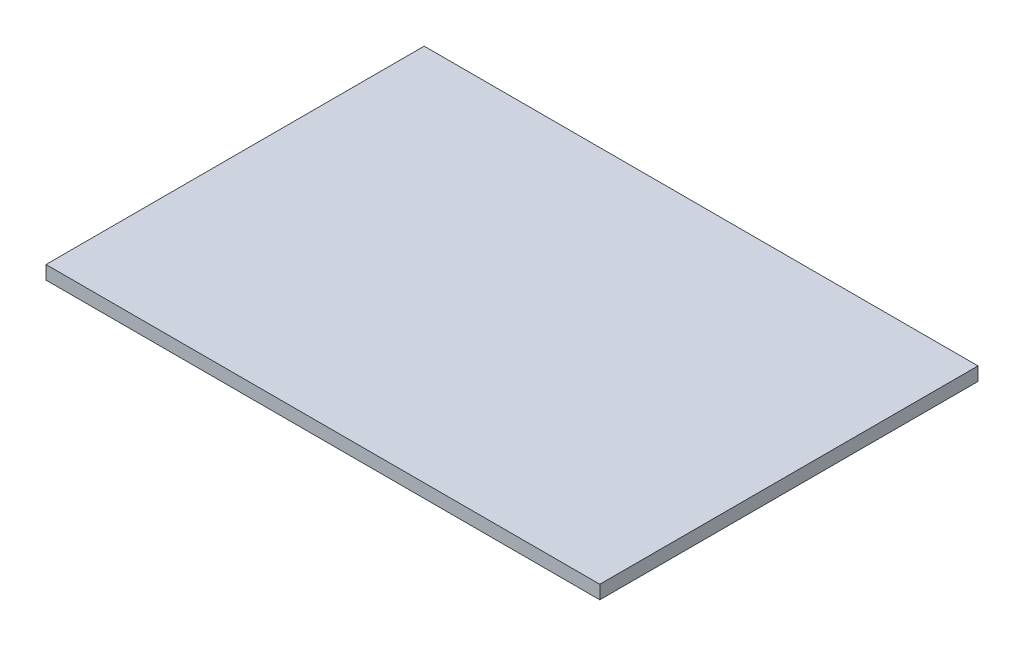
from build123d import *

# Parameters (mm, degrees)
SKETCH_1_W      = 41
SKETCH_1_H      = 28
EXTRUDE_1_DEPTH = 1


with BuildPart() as part:
    # Эскиз1 → Бобышка-Вытянуть1 (new body)
    with BuildSketch(Plane(origin=(0, 0, 0), x_dir=(1, 0, 0), z_dir=(0, 1, 0))):
        with Locations((20.5, 14)):
            Rectangle(SKETCH_1_W, SKETCH_1_H)
    extrude(amount=EXTRUDE_1_DEPTH)


solid = part.part
